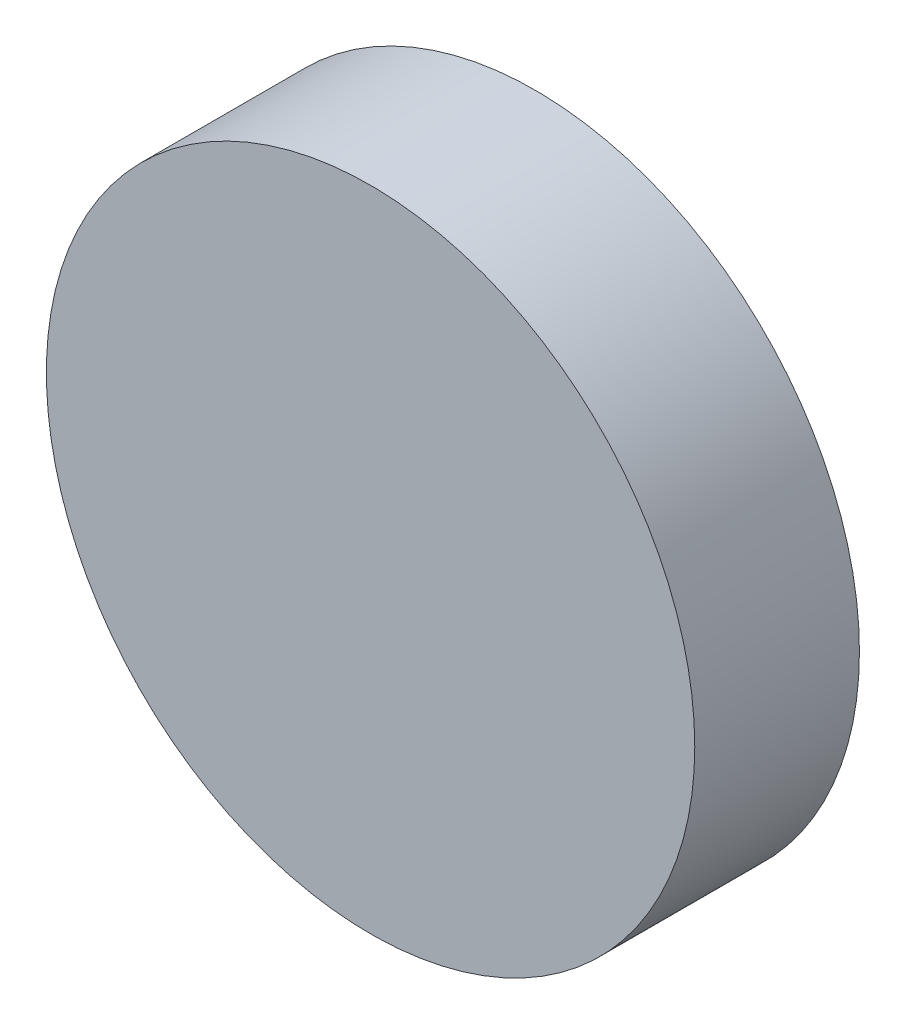
from build123d import *

# Parameters (mm, degrees)
SKETCH1_R           = 15.75
BOSS_EXTRUDE1_DEPTH = 8


with BuildPart() as part:
    # Sketch1 → Boss-Extrude1 (new body)
    with BuildSketch(Plane.XY):
        Circle(SKETCH1_R)
    extrude(amount=BOSS_EXTRUDE1_DEPTH)


solid = part.part
